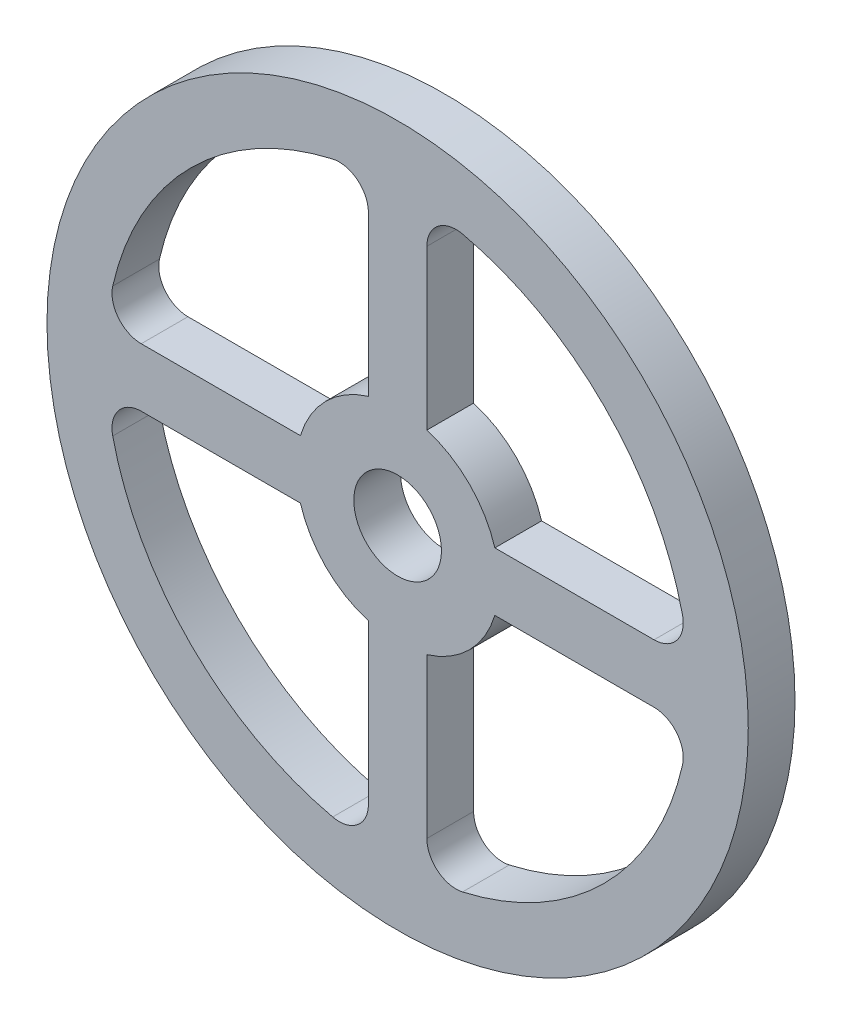
from build123d import *

# Parameters (mm, degrees)
SKETCH1_R           = 120
SKETCH1_R_2         = 15
BOSS_EXTRUDE3_DEPTH = 16


with BuildPart() as part:
    # Sketch1 → Boss-Extrude3 (new body)
    with BuildSketch(Plane.XY):
        Circle(SKETCH1_R)
        Circle(SKETCH1_R_2, mode=Mode.SUBTRACT)
        with BuildLine():
            Line((10, 87.745437009), (10, 33.268151895))
            ThreePointArc((10, 33.268151895), (24.563895563, 24.563895563), (33.268151895, 10))
            Line((33.268151895, 10), (87.745437009, 10))
            ThreePointArc((87.745437009, 10), (95.562828998, 13.763944958), (97.495374355, 22.222323503))
            ThreePointArc((97.495374355, 22.222323503), (70.707777798, 70.707777798), (22.222323503, 97.495374355))
            ThreePointArc((22.222323503, 97.495374355), (13.763944958, 95.562828998), (10, 87.745437009))
        make_face(mode=Mode.SUBTRACT)
        with BuildLine():
            Line((-10, 87.745437009), (-10, 33.268151895))
            ThreePointArc((-10, 33.268151895), (-24.563895563, 24.563895563), (-33.268151895, 10))
            Line((-33.268151895, 10), (-87.745437009, 10))
            ThreePointArc((-87.745437009, 10), (-95.562828998, 13.763944958), (-97.495374355, 22.222323503))
            ThreePointArc((-97.495374355, 22.222323503), (-70.707777798, 70.707777798), (-22.222323503, 97.495374355))
            ThreePointArc((-22.222323503, 97.495374355), (-13.763944958, 95.562828998), (-10, 87.745437009))
        make_face(mode=Mode.SUBTRACT)
        with BuildLine():
            Line((-10, -33.268151895), (-10, -87.745437009))
            ThreePointArc((-10, -87.745437009), (-13.763944958, -95.562828998), (-22.222323503, -97.495374355))
            ThreePointArc((-22.222323503, -97.495374355), (-70.707777798, -70.707777798), (-97.495374355, -22.222323503))
            ThreePointArc((-97.495374355, -22.222323503), (-95.562828998, -13.763944958), (-87.745437009, -10))
            Line((-87.745437009, -10), (-33.268151895, -10))
            ThreePointArc((-33.268151895, -10), (-24.563895563, -24.563895563), (-10, -33.268151895))
        make_face(mode=Mode.SUBTRACT)
        with BuildLine():
            Line((10, -33.268151895), (10, -87.745437009))
            ThreePointArc((10, -87.745437009), (13.763944958, -95.562828998), (22.222323503, -97.495374355))
            ThreePointArc((22.222323503, -97.495374355), (70.707777798, -70.707777798), (97.495374355, -22.222323503))
            ThreePointArc((97.495374355, -22.222323503), (95.562828998, -13.763944958), (87.745437009, -10))
            Line((87.745437009, -10), (33.268151895, -10))
            ThreePointArc((33.268151895, -10), (24.563895563, -24.563895563), (10, -33.268151895))
        make_face(mode=Mode.SUBTRACT)
    extrude(amount=BOSS_EXTRUDE3_DEPTH)


solid = part.part
